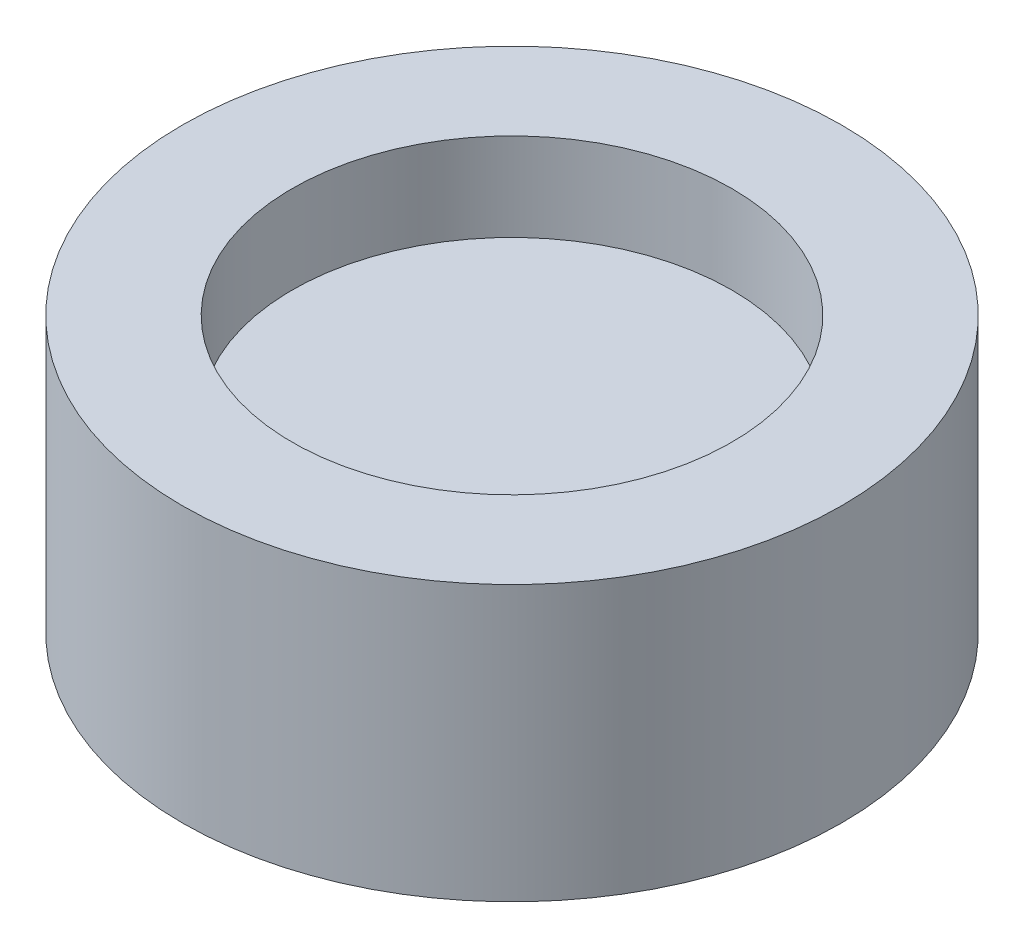
from build123d import *

# Parameters (mm, degrees)
ESBO_O3_R             = 8
CORTE_EXTRUS_O2_DEPTH = 10


with BuildPart() as part:
    # Esboço1 → Revolução1 (revolve)
    with BuildSketch(Plane.XY):
        Polygon((200, 250), (300, 250), (300, 0), (0, 0), (0, 170), (200, 170), align=None)
    revolve(axis=Axis((0, 0, 0), (0, 1, 0)))

    # Esboço3 → Corte-extrusão2 (cut)
    with BuildSketch(Plane.XZ):
        with Locations((-71, 55)):
            Circle(ESBO_O3_R)
        with Locations((71, 55)):
            Circle(ESBO_O3_R)
        with Locations((71, -55)):
            Circle(ESBO_O3_R)
        with Locations((-71, -55)):
            Circle(ESBO_O3_R)
    extrude(amount=-CORTE_EXTRUS_O2_DEPTH, mode=Mode.SUBTRACT)


solid = part.part
